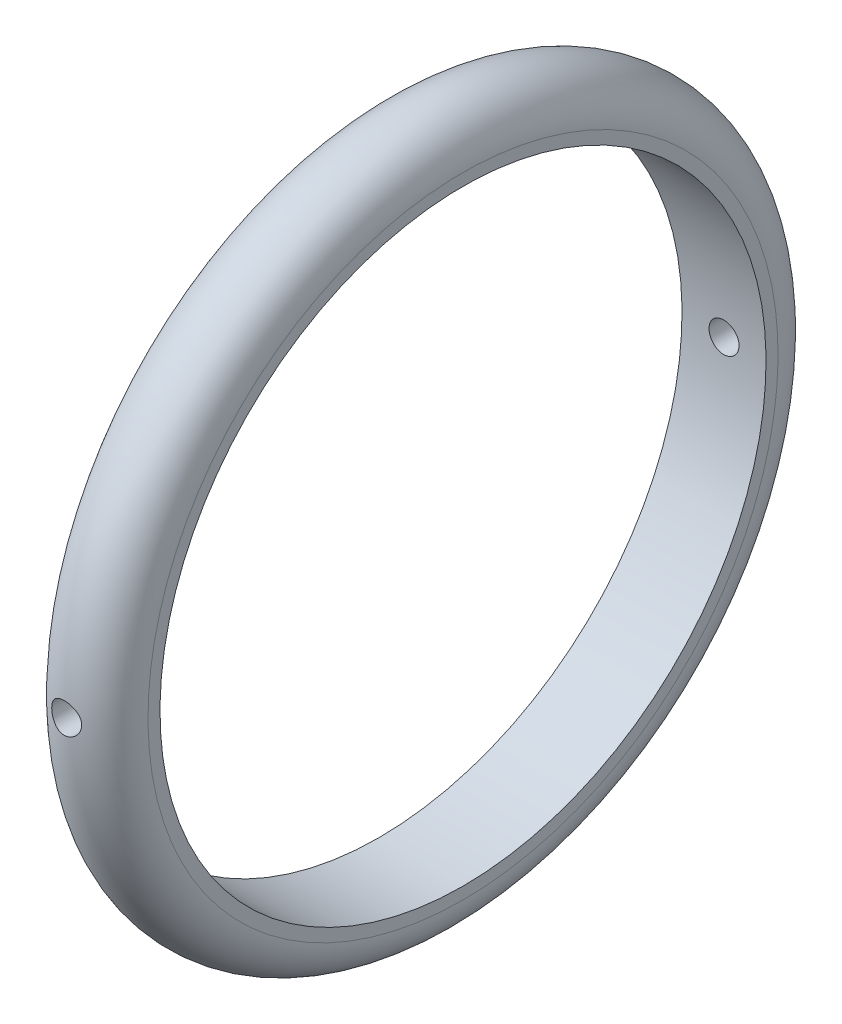
from build123d import *

# Parameters (mm, degrees)
SKETCH1_W                      = 14
SKETCH1_H                      = 2
CUT_EXTRUDE1_REACH             = 61.5
SKETCH1_3_R                    = 2.5
CUT_EXTRUDE1_DIRECTION_2_REACH = 61.5


with BuildPart() as part:
    # Sketch1 → Revolve1 (revolve)
    with BuildSketch(Plane.XY):
        with Locations((7, 51.5)):
            Rectangle(SKETCH1_W, SKETCH1_H)
        with BuildLine():
            ThreePointArc((0, 52.5), (7, 59.5), (14, 52.5))
            Line((14, 52.5), (0, 52.5))
        make_face()
    revolve(axis=Axis((0, 0, 0), (1, 0, 0)))

    # Sketch1_3 → Cut-Extrude1 (cut, up to next)
    with BuildSketch(Plane.XY, mode=Mode.PRIVATE) as cut_extrude1_sk1:
        with Locations((7, 0)):
            Circle(SKETCH1_3_R)
    cut_extrude1_tool1 = extrude(cut_extrude1_sk1.sketch, amount=-CUT_EXTRUDE1_REACH, mode=Mode.PRIVATE) & part.part
    add(cut_extrude1_tool1.solids().sort_by_distance((7, 0, 0))[0], mode=Mode.SUBTRACT)

    # Sketch1_3 → Cut-Extrude1 direction 2 (cut, up to next)
    with BuildSketch(Plane.XY, mode=Mode.PRIVATE) as cut_extrude1_direction_2_sk1:
        with Locations((7, 0)):
            Circle(SKETCH1_3_R)
    cut_extrude1_direction_2_tool1 = extrude(cut_extrude1_direction_2_sk1.sketch, amount=CUT_EXTRUDE1_DIRECTION_2_REACH, mode=Mode.PRIVATE) & part.part
    add(cut_extrude1_direction_2_tool1.solids().sort_by_distance((7, 0, 0))[0], mode=Mode.SUBTRACT)


solid = part.part
